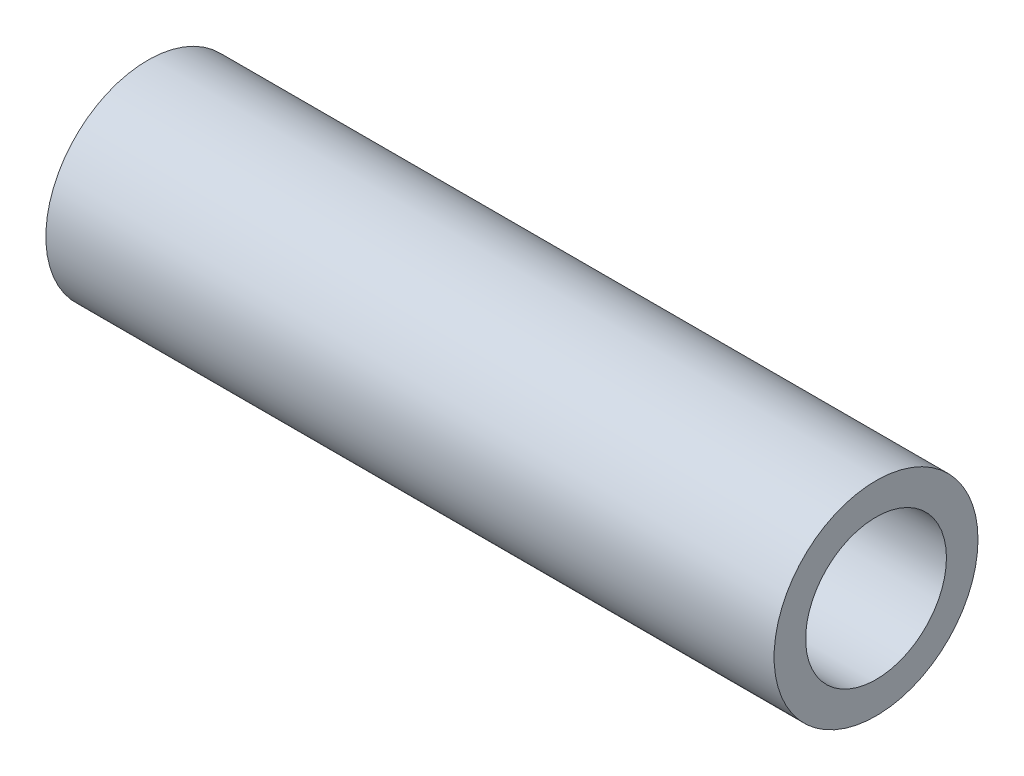
from build123d import *

# Parameters (mm, degrees)
SKETCH1_R           = 10.668
SKETCH1_R_2         = 7.366
BOSS_EXTRUDE1_DEPTH = 76.2


with BuildPart() as part:
    # Sketch1 → Boss-Extrude1 (new body)
    with BuildSketch(Plane(origin=(0, 0, 0), x_dir=(0, 0, -1), z_dir=(1, 0, 0))):
        Circle(SKETCH1_R)
        Circle(SKETCH1_R_2, mode=Mode.SUBTRACT)
    extrude(amount=-BOSS_EXTRUDE1_DEPTH)


solid = part.part
